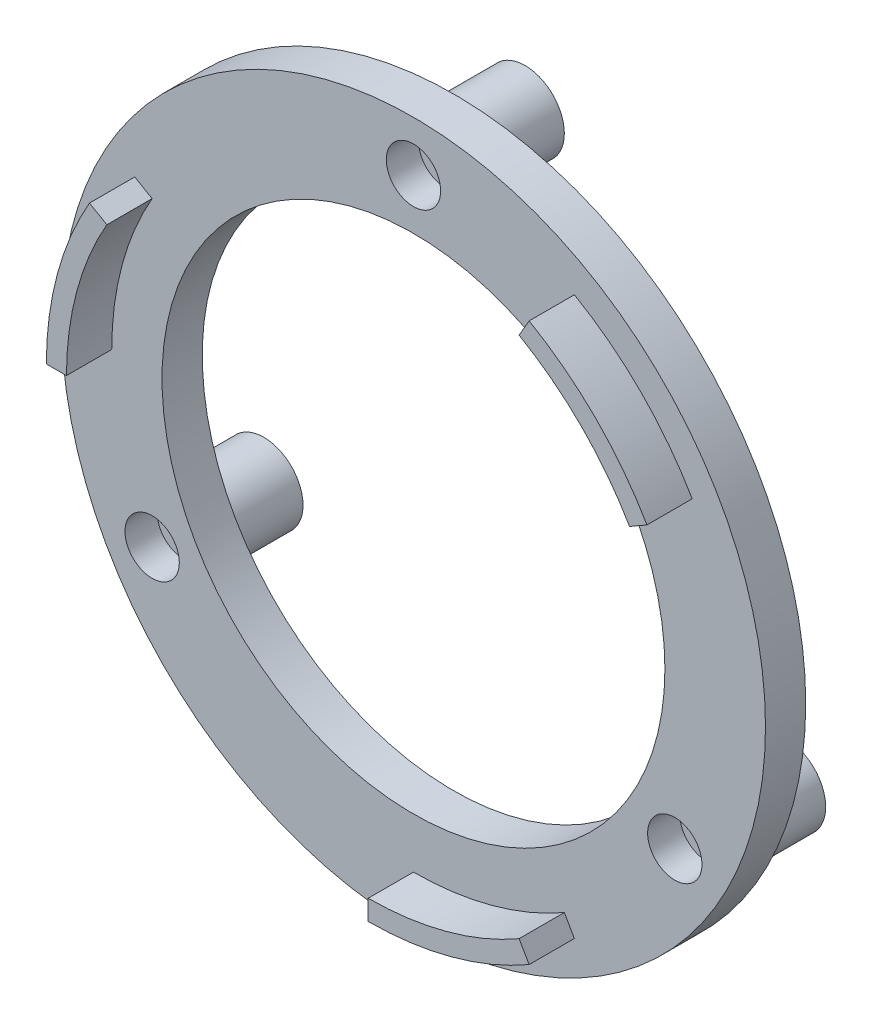
from build123d import *

# Parameters (mm, degrees)
SKETCH1_R           = 35
SKETCH1_R_2         = 30
SKETCH1_R_3         = 25
BOSS_EXTRUDE1_DEPTH = 4
SKETCH2_R           = 3.9
BOSS_EXTRUDE2_DEPTH = 7.1
SKETCH3_R           = 1.6
CUT_EXTRUDE1_DEPTH  = 15
SKETCH4_R           = 2.7
CUT_EXTRUDE2_DEPTH  = 3.2
BOSS_EXTRUDE3_DEPTH = 4.5
BOSS_EXTRUDE4_DEPTH = 4.5


with BuildPart() as part:
    # Sketch1 → Boss-Extrude1 (new body)
    with BuildSketch(Plane.XY):
        Circle(SKETCH1_R)
        Circle(SKETCH1_R_2, mode=Mode.SUBTRACT)
        Circle(SKETCH1_R_2)
        Circle(SKETCH1_R_3, mode=Mode.SUBTRACT)
    extrude(amount=BOSS_EXTRUDE1_DEPTH)

    # Sketch2 → Boss-Extrude2 (add)
    with BuildSketch(Plane(origin=(0, 0, 0), x_dir=(-1, 0, 0), z_dir=(0, 0, -1))):
        with Locations((0, 30)):
            Circle(SKETCH2_R)
        with Locations((25.980762114, -15)):
            Circle(SKETCH2_R)
        with Locations((-25.980762114, -15)):
            Circle(SKETCH2_R)
    extrude(amount=BOSS_EXTRUDE2_DEPTH)

    # Sketch3 → Cut-Extrude1 (cut)
    with BuildSketch(Plane(origin=(0, 0, -7.1), x_dir=(-1, 0, 0), z_dir=(0, 0, -1))):
        with Locations((0, 30)):
            Circle(SKETCH3_R)
        with Locations((25.980762114, -15)):
            Circle(SKETCH3_R)
        with Locations((-25.980762114, -15)):
            Circle(SKETCH3_R)
    extrude(amount=-CUT_EXTRUDE1_DEPTH, mode=Mode.SUBTRACT)

    # Sketch4 → Cut-Extrude2 (cut)
    with BuildSketch(Plane.XY.offset(4)):
        with Locations((0, 30)):
            Circle(SKETCH4_R)
        with Locations((25.980762114, -15)):
            Circle(SKETCH4_R)
        with Locations((-25.980762114, -15)):
            Circle(SKETCH4_R)
    extrude(amount=-CUT_EXTRUDE2_DEPTH, mode=Mode.SUBTRACT)

    # Sketch6 → Boss-Extrude3 (add)
    with BuildSketch(Plane.XY.offset(4)):
        with BuildLine():
            Line((25.980762114, 15), (27.712812921, 16))
            ThreePointArc((27.712812921, 16), (22.627416998, 22.627416998), (16, 27.712812921))
            Line((16, 27.712812921), (15, 25.980762114))
            ThreePointArc((15, 25.980762114), (21.213203436, 21.213203436), (25.980762114, 15))
        make_face()
    extrude(amount=BOSS_EXTRUDE3_DEPTH)

    # Sketch7 → Boss-Extrude4 (add)
    with BuildSketch(Plane.XY.offset(4)):
        with BuildLine():
            Line((16, -27.712812921), (15, -25.980762114))
            ThreePointArc((15, -25.980762114), (7.764571353, -28.977774789), (0, -30))
            Line((0, -30), (0, -32))
            ThreePointArc((0, -32), (8.282209443, -30.909626441), (16, -27.712812921))
        make_face()
        with BuildLine():
            Line((25.980762114, 15), (27.712812921, 16))
            ThreePointArc((27.712812921, 16), (22.627416998, 22.627416998), (16, 27.712812921))
            Line((16, 27.712812921), (15, 25.980762114))
            ThreePointArc((15, 25.980762114), (21.213203436, 21.213203436), (25.980762114, 15))
        make_face()
        with BuildLine():
            Line((-32, 0), (-30, 0))
            ThreePointArc((-30, 0), (-28.977774789, 7.764571353), (-25.980762114, 15))
            Line((-25.980762114, 15), (-27.712812921, 16))
            ThreePointArc((-27.712812921, 16), (-30.909626441, 8.282209443), (-32, 0))
        make_face()
    extrude(amount=BOSS_EXTRUDE4_DEPTH)


solid = part.part
